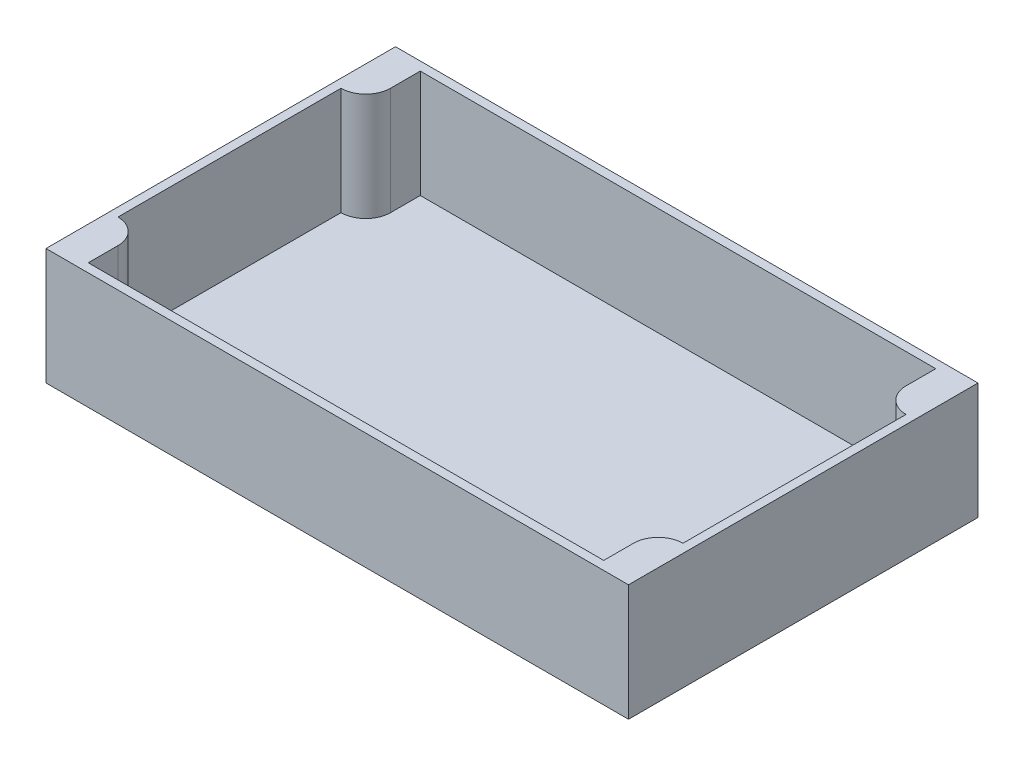
from build123d import *

# Parameters (mm, degrees)
SKETCH1_W           = 200
SKETCH1_H           = 120
BOSS_EXTRUDE1_DEPTH = 3
SKETCH2_W           = 200
SKETCH2_H           = 120
BOSS_EXTRUDE2_DEPTH = 37


with BuildPart() as part:
    # Sketch1 → Boss-Extrude1 (new body)
    with BuildSketch(Plane(origin=(0, 0, 0), x_dir=(1, 0, 0), z_dir=(0, 1, 0))):
        with Locations((100, 60)):
            Rectangle(SKETCH1_W, SKETCH1_H)
    extrude(amount=BOSS_EXTRUDE1_DEPTH)

    # Sketch2 → Boss-Extrude2 (add)
    with BuildSketch(Plane(origin=(0, 3, 0), x_dir=(1, 0, 0), z_dir=(0, 1, 0))):
        with Locations((100, 60)):
            Rectangle(SKETCH2_W, SKETCH2_H)
        with BuildLine():
            Line((3, 98.3), (3, 21.7))
            ThreePointArc((3, 21.7), (9.01040764, 19.21040764), (11.5, 13.2))
            Line((11.5, 13.2), (11.5, 3))
            Line((11.5, 3), (188.5, 3))
            Line((188.5, 3), (188.5, 13.2))
            ThreePointArc((188.5, 13.2), (190.98959236, 19.21040764), (197, 21.7))
            Line((197, 21.7), (197, 98.3))
            ThreePointArc((197, 98.3), (190.98959236, 100.78959236), (188.5, 106.8))
            Line((188.5, 106.8), (188.5, 117))
            Line((188.5, 117), (11.5, 117))
            Line((11.5, 117), (11.5, 106.8))
            ThreePointArc((11.5, 106.8), (9.01040764, 100.78959236), (3, 98.3))
        make_face(mode=Mode.SUBTRACT)
    extrude(amount=BOSS_EXTRUDE2_DEPTH)


solid = part.part
